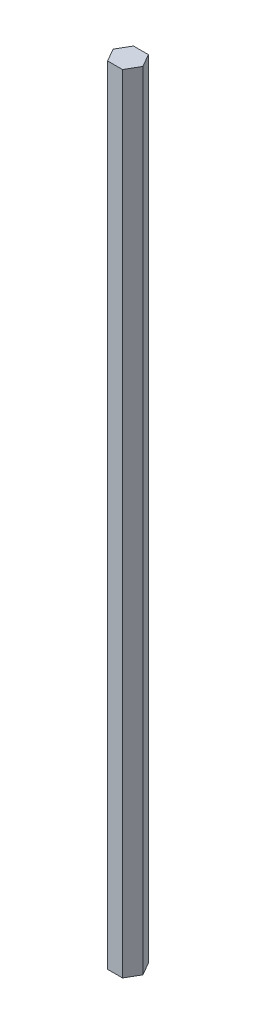
from build123d import *

# Parameters (mm, degrees)
BOSS_EXTRUDE1_DEPTH = 355.6


with BuildPart() as part:
    # Sketch1 → Boss-Extrude1 (new body)
    with BuildSketch(Plane(origin=(0, 0, 0), x_dir=(1, 0, 0), z_dir=(0, 1, 0))):
        Polygon((0.120257632, -2.386475767), (3.493377632, 3.455939453), (0.120257632, 9.298354673), (-6.625982368, 9.298354673), (-9.999102368, 3.455939453), (-6.625982368, -2.386475767), align=None)
    extrude(amount=BOSS_EXTRUDE1_DEPTH)


solid = part.part
